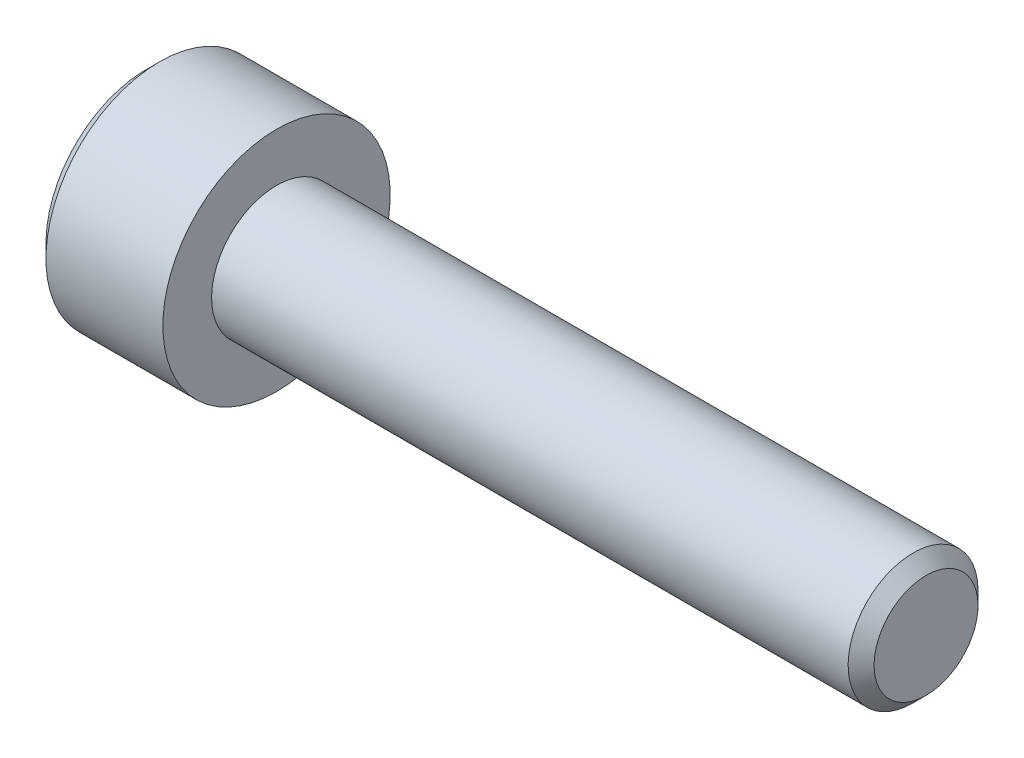
from build123d import *

# Parameters (mm, degrees)
CHAMFER1_SIZE      = 0.4
CUT_EXTRUDE1_DEPTH = 2


with BuildPart() as part:
    # Sketch1 → Revolve1 (revolve)
    with BuildSketch(Plane.XY):
        Polygon((-4, 0), (-4, 3.1), (-3.6, 3.5), (0, 3.5), (0, 2), (20, 2), (20, 0), align=None)
    revolve(axis=Axis((20, 0, 0), (-1, 0, 0)))

    # Chamfer1
    chamfer1_edges = [part.edges().sort_by_distance(p)[0] for p in [
        (20, -2, 0),
    ]]
    chamfer(chamfer1_edges, length=CHAMFER1_SIZE)

    # Sketch2 → Cut-Revolve1 (revolve, cut)
    with BuildSketch(Plane.XY):
        Polygon((-4, 0), (-4, 1.5), (-2, 1.5), (-1.598076211, 0), align=None)
    revolve(axis=Axis((-1.598076211, 0, 0), (-1, 0, 0)), mode=Mode.SUBTRACT)

    # Sketch3 → Cut-Extrude1 (cut)
    with BuildSketch(Plane(origin=(-4, 0, 0), x_dir=(0, 0, -1), z_dir=(1, 0, 0))):
        Polygon((-1.5, 0.866025404), (-1.5, -0.866025404), (0, -1.732050808), (1.5, -0.866025404), (1.5, 0.866025404), (0, 1.732050808), align=None)
    extrude(amount=CUT_EXTRUDE1_DEPTH, mode=Mode.SUBTRACT)


solid = part.part
